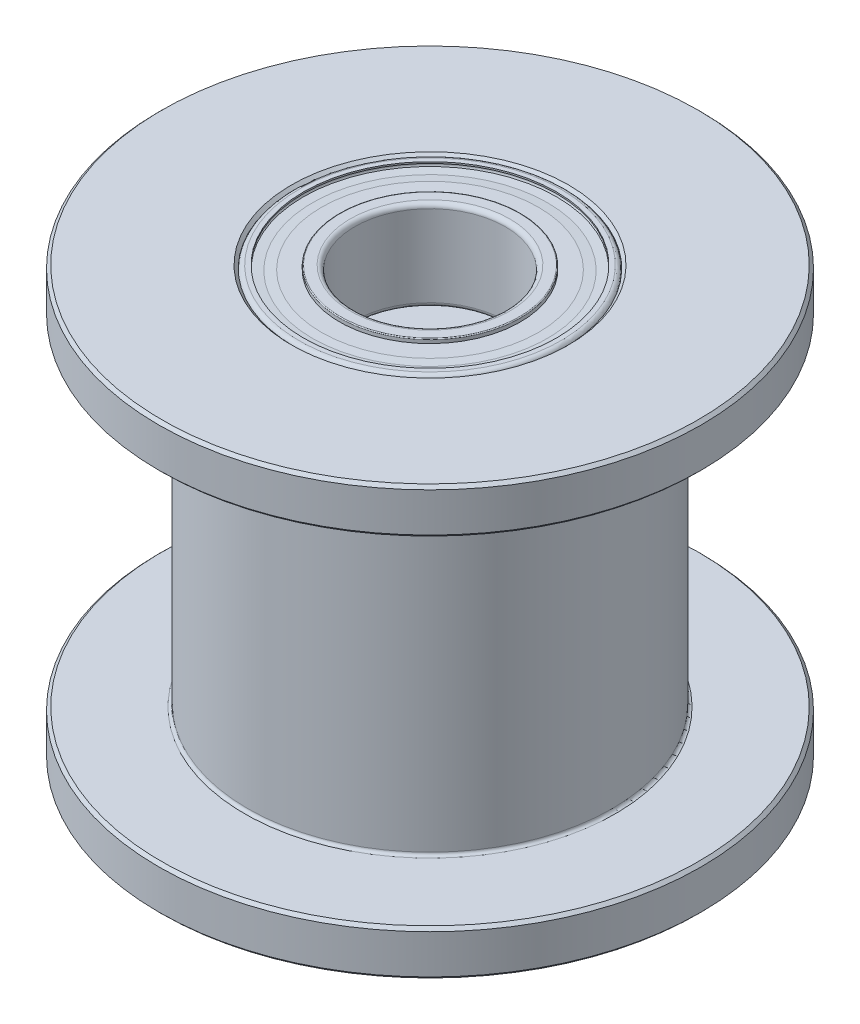
from build123d import *

# Parameters (mm, degrees)
ZKOSEN_1_SIZE      = 0.1
ZAOBLIT1_R         = 0.1
KRUHOV_POLE1_COUNT = 8
KRUHOV_POLE3_COUNT = 8


with BuildPart() as part:
    # Skica1 → Rotovat1 (revolve)
    with BuildSketch(Plane.XY):
        Polygon((4.5, 14.2), (9, 14.2), (9, 12.7), (6.05, 12.7), (6.05, 1.5), (9, 1.5), (9, 0), (4.5, 0), (4.5, 3), (1.5, 3), (1.5, 11.2), (4.5, 11.2), align=None)
    revolve(axis=Axis((0, 0, 0), (0, -1, 0)))

    # Zkosení1
    zkosen_1_edges = [part.edges().sort_by_distance(p)[0] for p in [
        (-1.5, 3, 0),
        (-4.5, 0, 0),
        (-9, 0, 0),
        (-9, 1.5, 0),
        (-9, 12.7, 0),
        (-9, 14.2, 0),
        (-4.5, 14.2, 0),
        (-1.5, 11.2, 0),
    ]]
    chamfer(zkosen_1_edges, length=ZKOSEN_1_SIZE)

    # Zaoblit1
    zaoblit1_edges = [part.edges().sort_by_distance(p)[0] for p in [
        (-4.5, 3, 0),
        (-6.05, 1.5, 0),
        (-6.05, 12.7, 0),
        (-4.5, 11.2, 0),
    ]]
    fillet(zaoblit1_edges, radius=ZAOBLIT1_R)


with BuildPart() as body_2:
    # Skica4 → Rotovat2 (revolve)
    with BuildSketch(Plane.XY):
        with BuildLine():
            Line((4.5, 14.05), (4.5, 11.35))
            ThreePointArc((4.5, 11.35), (4.456066017, 11.243933983), (4.35, 11.2))
            Line((4.35, 11.2), (4.2, 11.2))
            Line((4.2, 11.2), (4.2, 11.25))
            ThreePointArc((4.2, 11.25), (4.289757174, 11.333393211), (4.213177928, 11.429030007))
            Line((4.213177928, 11.429030007), (3.85, 11.482786405))
            Line((3.85, 11.482786405), (3.85, 12.252786405))
            ThreePointArc((3.85, 12.252786405), (4.05, 12.7), (3.85, 13.147213595))
            Line((3.85, 13.147213595), (3.85, 13.917213595))
            Line((3.85, 13.917213595), (4.213177928, 13.970969993))
            ThreePointArc((4.213177928, 13.970969993), (4.289757174, 14.066606789), (4.2, 14.15))
            Line((4.2, 14.15), (4.2, 14.2))
            Line((4.2, 14.2), (4.35, 14.2))
            ThreePointArc((4.35, 14.2), (4.456066017, 14.156066017), (4.5, 14.05))
        make_face()
    revolve(axis=Axis((0, 0, 0), (0, 1, 0)))


with BuildPart() as body_3:
    # Skica5 → Rotovat3 (revolve)
    with BuildSketch(Plane.XY):
        with BuildLine():
            Line((2.5, 14.05), (2.5, 11.35))
            ThreePointArc((2.5, 11.35), (2.543933983, 11.243933983), (2.65, 11.2))
            Line((2.65, 11.2), (2.97, 11.2))
            ThreePointArc((2.97, 11.2), (2.991213203, 11.208786797), (3, 11.23))
            Line((3, 11.23), (3, 11.34))
            Line((3, 11.34), (3.6, 11.34))
            Line((3.6, 11.34), (3.896185034, 11.391714847))
            Line((3.896185034, 11.391714847), (4.192370069, 11.34))
            Line((4.192370069, 11.34), (4.192370069, 11.39))
            Line((4.192370069, 11.39), (3.897467562, 11.458062558))
            Line((3.897467562, 11.458062558), (3.597467562, 11.458062558))
            Line((3.597467562, 11.458062558), (3, 11.39))
            Line((3, 11.39), (3, 12.303137303))
            ThreePointArc((3, 12.303137303), (2.85, 12.7), (3, 13.096862697))
            Line((3, 13.096862697), (3, 14.01))
            Line((3, 14.01), (3.6, 13.97))
            Line((3.6, 13.97), (3.9, 13.97))
            Line((3.9, 13.97), (4.2, 14.01))
            Line((4.2, 14.01), (4.2, 14.06))
            Line((4.2, 14.06), (3.9, 14.04))
            Line((3.9, 14.04), (3.6, 14.06))
            Line((3.6, 14.06), (3, 14.06))
            Line((3, 14.06), (3, 14.17))
            ThreePointArc((3, 14.17), (2.991213203, 14.191213203), (2.97, 14.2))
            Line((2.97, 14.2), (2.65, 14.2))
            ThreePointArc((2.65, 14.2), (2.543933983, 14.156066017), (2.5, 14.05))
        make_face()
    revolve(axis=Axis((0, 0, 0), (0, 1, 0)))


with BuildPart() as body_4:
    # Skica6 → Rotovat4 (revolve)
    with BuildSketch(Plane.XY):
        with BuildLine():
            Line((3.45, 13.3), (3.45, 12.1))
            ThreePointArc((3.45, 12.1), (4.05, 12.7), (3.45, 13.3))
        make_face()
    revolve(axis=Axis((3.45, 13.3, 0), (0, -1, 0)))


with BuildPart() as kruhov_pole1_1:
    # Kruhové pole1: pattern copy
    add(body_4.part.rotate(Axis((0, 0, 0), (0, 1, 0)), 1 * 360 / KRUHOV_POLE1_COUNT))


with BuildPart() as kruhov_pole1_2:
    # Kruhové pole1: pattern copy
    add(body_4.part.rotate(Axis((0, 0, 0), (0, 1, 0)), 2 * 360 / KRUHOV_POLE1_COUNT))


with BuildPart() as kruhov_pole1_3:
    # Kruhové pole1: pattern copy
    add(body_4.part.rotate(Axis((0, 0, 0), (0, 1, 0)), 3 * 360 / KRUHOV_POLE1_COUNT))


with BuildPart() as kruhov_pole1_4:
    # Kruhové pole1: pattern copy
    add(body_4.part.rotate(Axis((0, 0, 0), (0, 1, 0)), 4 * 360 / KRUHOV_POLE1_COUNT))


with BuildPart() as kruhov_pole1_5:
    # Kruhové pole1: pattern copy
    add(body_4.part.rotate(Axis((0, 0, 0), (0, 1, 0)), 5 * 360 / KRUHOV_POLE1_COUNT))


with BuildPart() as kruhov_pole1_6:
    # Kruhové pole1: pattern copy
    add(body_4.part.rotate(Axis((0, 0, 0), (0, 1, 0)), 6 * 360 / KRUHOV_POLE1_COUNT))


with BuildPart() as kruhov_pole1_7:
    # Kruhové pole1: pattern copy
    add(body_4.part.rotate(Axis((0, 0, 0), (0, 1, 0)), 7 * 360 / KRUHOV_POLE1_COUNT))


with BuildPart() as body_12:
    # Skica7 → Rotovat5 (revolve)
    with BuildSketch(Plane.XY):
        with BuildLine():
            Line((4.5, 2.85), (4.5, 0.15))
            ThreePointArc((4.5, 0.15), (4.456066017, 0.043933983), (4.35, 0))
            Line((4.35, 0), (4.2, 0))
            Line((4.2, 0), (4.2, 0.05))
            ThreePointArc((4.2, 0.05), (4.289757174, 0.133393211), (4.213177928, 0.229030007))
            Line((4.213177928, 0.229030007), (3.85, 0.282786405))
            Line((3.85, 0.282786405), (3.85, 1.052786405))
            ThreePointArc((3.85, 1.052786405), (4.05, 1.5), (3.85, 1.947213595))
            Line((3.85, 1.947213595), (3.85, 2.717213595))
            Line((3.85, 2.717213595), (4.213177928, 2.770969993))
            ThreePointArc((4.213177928, 2.770969993), (4.289757174, 2.866606789), (4.2, 2.95))
            Line((4.2, 2.95), (4.2, 3))
            Line((4.2, 3), (4.35, 3))
            ThreePointArc((4.35, 3), (4.456066017, 2.956066017), (4.5, 2.85))
        make_face()
    revolve(axis=Axis((0, 0, 0), (0, 1, 0)))


with BuildPart() as body_13:
    # Skica8 → Rotovat6 (revolve)
    with BuildSketch(Plane.XY):
        with BuildLine():
            Line((2.5, 2.85), (2.5, 0.15))
            ThreePointArc((2.5, 0.15), (2.543933983, 0.043933983), (2.65, 0))
            Line((2.65, 0), (2.97, 0))
            ThreePointArc((2.97, 0), (2.991213203, 0.008786797), (3, 0.03))
            Line((3, 0.03), (3, 0.14))
            Line((3, 0.14), (3.6, 0.14))
            Line((3.6, 0.14), (3.896185034, 0.191714847))
            Line((3.896185034, 0.191714847), (4.192370069, 0.14))
            Line((4.192370069, 0.14), (4.192370069, 0.19))
            Line((4.192370069, 0.19), (3.897467562, 0.258062558))
            Line((3.897467562, 0.258062558), (3.597467562, 0.258062558))
            Line((3.597467562, 0.258062558), (3, 0.19))
            Line((3, 0.19), (3, 1.103137303))
            ThreePointArc((3, 1.103137303), (2.85, 1.5), (3, 1.896862697))
            Line((3, 1.896862697), (3, 2.81))
            Line((3, 2.81), (3.6, 2.77))
            Line((3.6, 2.77), (3.9, 2.77))
            Line((3.9, 2.77), (4.2, 2.81))
            Line((4.2, 2.81), (4.2, 2.86))
            Line((4.2, 2.86), (3.9, 2.84))
            Line((3.9, 2.84), (3.6, 2.86))
            Line((3.6, 2.86), (3, 2.86))
            Line((3, 2.86), (3, 2.97))
            ThreePointArc((3, 2.97), (2.991213203, 2.991213203), (2.97, 3))
            Line((2.97, 3), (2.65, 3))
            ThreePointArc((2.65, 3), (2.543933983, 2.956066017), (2.5, 2.85))
        make_face()
    revolve(axis=Axis((0, 0, 0), (0, -1, 0)))


with BuildPart() as body_14:
    # Skica9 → Rotovat7 (revolve)
    with BuildSketch(Plane.XY):
        with BuildLine():
            Line((3.45, 2.1), (3.45, 0.9))
            ThreePointArc((3.45, 0.9), (4.05, 1.5), (3.45, 2.1))
        make_face()
    revolve(axis=Axis((3.45, 2.1, 0), (0, -1, 0)))


with BuildPart() as kruhov_pole3_1:
    # Kruhové pole3: pattern copy
    add(body_14.part.rotate(Axis((0, 0, 0), (0, 1, 0)), 1 * 360 / KRUHOV_POLE3_COUNT))


with BuildPart() as kruhov_pole3_2:
    # Kruhové pole3: pattern copy
    add(body_14.part.rotate(Axis((0, 0, 0), (0, 1, 0)), 2 * 360 / KRUHOV_POLE3_COUNT))


with BuildPart() as kruhov_pole3_3:
    # Kruhové pole3: pattern copy
    add(body_14.part.rotate(Axis((0, 0, 0), (0, 1, 0)), 3 * 360 / KRUHOV_POLE3_COUNT))


with BuildPart() as kruhov_pole3_4:
    # Kruhové pole3: pattern copy
    add(body_14.part.rotate(Axis((0, 0, 0), (0, 1, 0)), 4 * 360 / KRUHOV_POLE3_COUNT))


with BuildPart() as kruhov_pole3_5:
    # Kruhové pole3: pattern copy
    add(body_14.part.rotate(Axis((0, 0, 0), (0, 1, 0)), 5 * 360 / KRUHOV_POLE3_COUNT))


with BuildPart() as kruhov_pole3_6:
    # Kruhové pole3: pattern copy
    add(body_14.part.rotate(Axis((0, 0, 0), (0, 1, 0)), 6 * 360 / KRUHOV_POLE3_COUNT))


with BuildPart() as kruhov_pole3_7:
    # Kruhové pole3: pattern copy
    add(body_14.part.rotate(Axis((0, 0, 0), (0, 1, 0)), 7 * 360 / KRUHOV_POLE3_COUNT))


solid = Compound([part.part, body_2.part, body_3.part, body_4.part, kruhov_pole1_1.part, kruhov_pole1_2.part, kruhov_pole1_3.part, kruhov_pole1_4.part, kruhov_pole1_5.part, kruhov_pole1_6.part, kruhov_pole1_7.part, body_12.part, body_13.part, body_14.part, kruhov_pole3_1.part, kruhov_pole3_2.part, kruhov_pole3_3.part, kruhov_pole3_4.part, kruhov_pole3_5.part, kruhov_pole3_6.part, kruhov_pole3_7.part])
